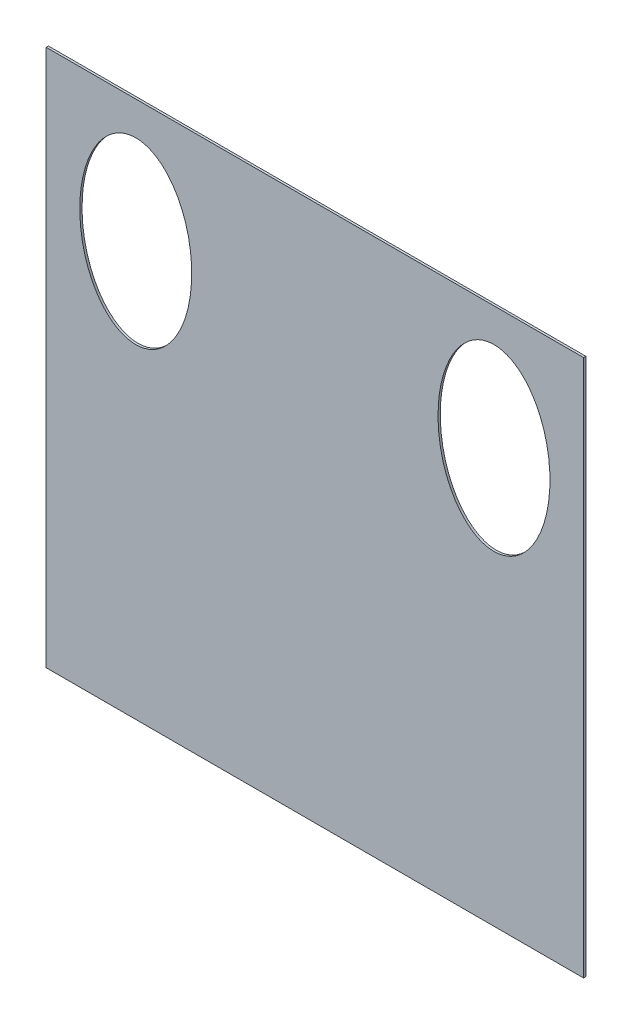
from build123d import *

# Parameters (mm, degrees)
SKETCH1_W           = 609.6
SKETCH1_H           = 609.6
BOSS_EXTRUDE1_DEPTH = 2.54
SKETCH2_RX          = 101.6
SKETCH2_RY          = 63.5
CUT_EXTRUDE1_DEPTH  = 3.54


with BuildPart() as part:
    # Sketch1 → Boss-Extrude1 (new body)
    with BuildSketch(Plane.XY):
        with Locations((120.912396694, -5.667768595)):
            Rectangle(SKETCH1_W, SKETCH1_H)
    extrude(amount=BOSS_EXTRUDE1_DEPTH)

    # Sketch2 → Cut-Extrude1 (cut, through all)
    with BuildSketch(Plane.XY.offset(2.54)):
        with Locations(Location((-82.287603306, 159.432231405), (0, 0, -90))):
            Ellipse(SKETCH2_RX, SKETCH2_RY)
        with Locations(Location((324.112396694, 159.432231405), (0, 0, -90))):
            Ellipse(SKETCH2_RX, SKETCH2_RY)
    extrude(amount=-CUT_EXTRUDE1_DEPTH, mode=Mode.SUBTRACT)


solid = part.part
